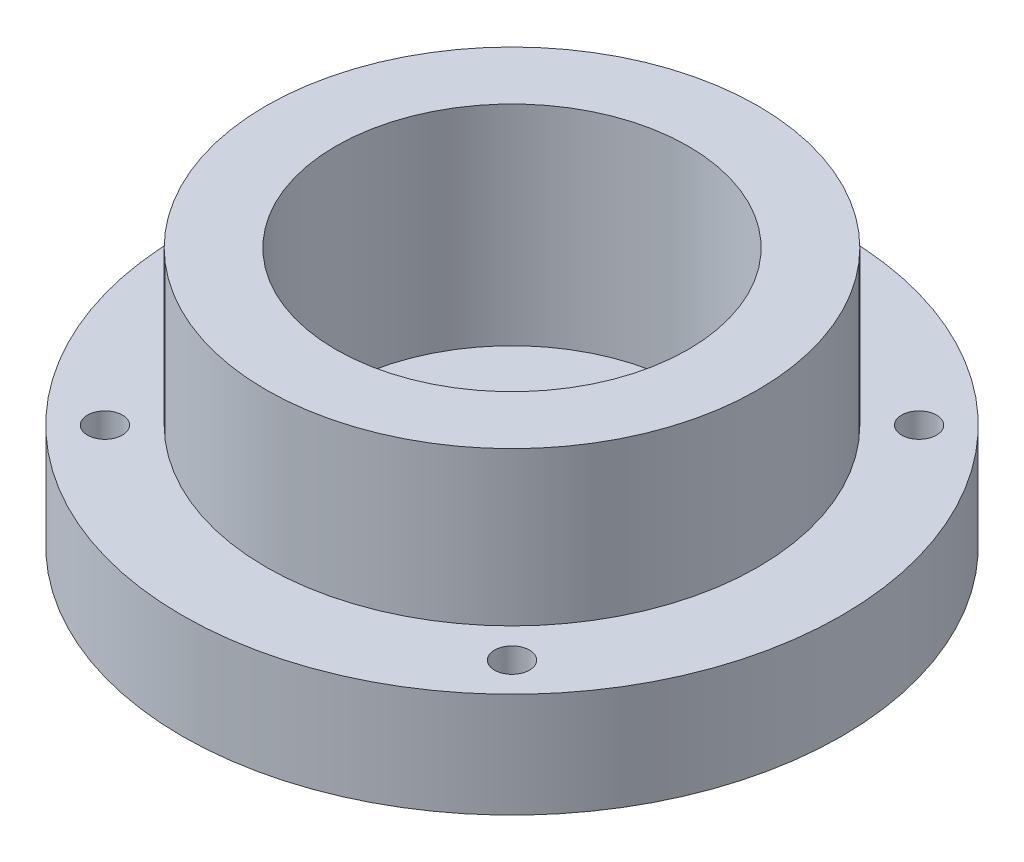
from build123d import *

# Parameters (mm, degrees)
SKETCH1_R           = 35.25
SKETCH1_R_2         = 15.5
BOSS_EXTRUDE1_DEPTH = 7
SKETCH2_R           = 35.25
SKETCH2_R_2         = 25.25
BOSS_EXTRUDE2_DEPTH = 30
SKETCH3_R           = 2.5
CUT_EXTRUDE1_DEPTH  = 7
SKETCH4_R           = 47.25
SKETCH4_R_2         = 35.25
BOSS_EXTRUDE3_DEPTH = 15
SKETCH5_R           = 2.5
CUT_EXTRUDE2_DEPTH  = 15


with BuildPart() as part:
    # Sketch1 → Boss-Extrude1 (new body)
    with BuildSketch(Plane(origin=(0, 0, 0), x_dir=(1, 0, 0), z_dir=(0, 1, 0))):
        Circle(SKETCH1_R)
        Circle(SKETCH1_R_2, mode=Mode.SUBTRACT)
    extrude(amount=BOSS_EXTRUDE1_DEPTH)

    # Sketch2 → Boss-Extrude2 (add)
    with BuildSketch(Plane(origin=(0, 7, 0), x_dir=(1, 0, 0), z_dir=(0, 1, 0))):
        Circle(SKETCH2_R)
        Circle(SKETCH2_R_2, mode=Mode.SUBTRACT)
    extrude(amount=BOSS_EXTRUDE2_DEPTH)

    # Sketch3 → Cut-Extrude1 (cut)
    with BuildSketch(Plane(origin=(0, 7, 0), x_dir=(1, 0, 0), z_dir=(0, 1, 0))):
        with Locations((0, 20)):
            Circle(SKETCH3_R)
        with Locations((20, 0)):
            Circle(SKETCH3_R)
        with Locations((0, -20)):
            Circle(SKETCH3_R)
        with Locations((-20, 0)):
            Circle(SKETCH3_R)
    extrude(amount=-CUT_EXTRUDE1_DEPTH, mode=Mode.SUBTRACT)

    # Sketch4 → Boss-Extrude3 (add)
    with BuildSketch(Plane.XZ):
        Circle(SKETCH4_R)
        Circle(SKETCH4_R_2, mode=Mode.SUBTRACT)
    extrude(amount=-BOSS_EXTRUDE3_DEPTH)

    # Sketch5 → Cut-Extrude2 (cut)
    with BuildSketch(Plane.XZ):
        with Locations((29.168154724, 29.168154724)):
            Circle(SKETCH5_R)
        with Locations((29.168154724, -29.168154724)):
            Circle(SKETCH5_R)
        with Locations((-29.168154724, -29.168154724)):
            Circle(SKETCH5_R)
        with Locations((-29.168154724, 29.168154724)):
            Circle(SKETCH5_R)
    extrude(amount=-CUT_EXTRUDE2_DEPTH, mode=Mode.SUBTRACT)


solid = part.part
